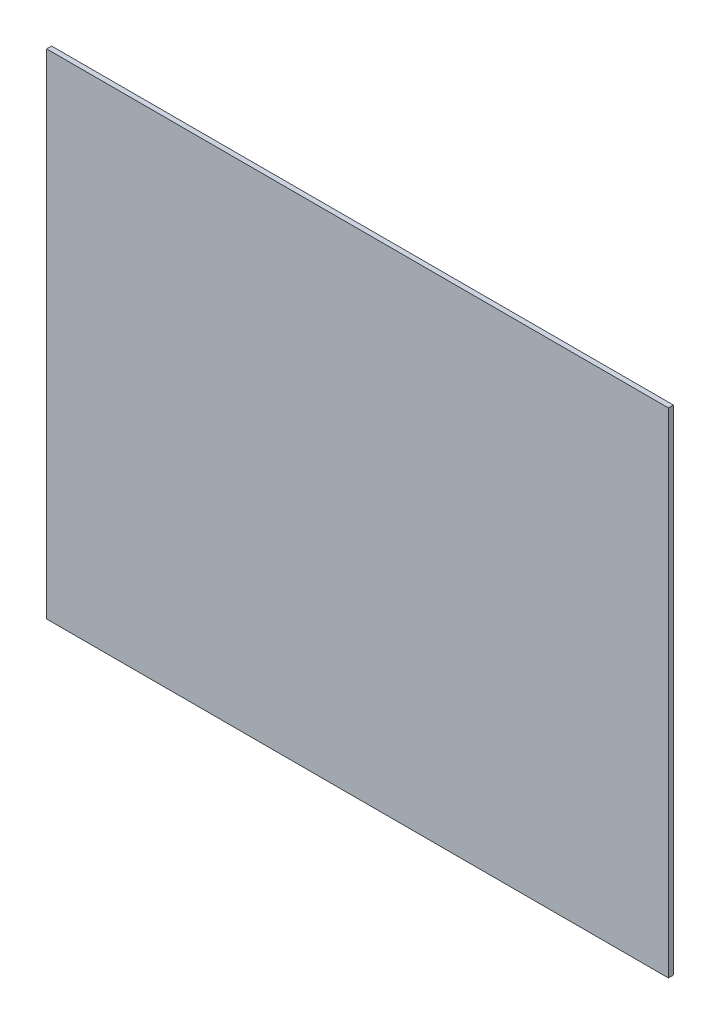
from build123d import *

# Parameters (mm, degrees)
CROQUIS1_W              = 250
CROQUIS1_H              = 198.5
SALIENTE_EXTRUIR1_DEPTH = 2


with BuildPart() as part:
    # Croquis1 → Saliente-Extruir1 (new body)
    with BuildSketch(Plane.XY):
        Rectangle(CROQUIS1_W, CROQUIS1_H)
    extrude(amount=SALIENTE_EXTRUIR1_DEPTH)


solid = part.part
